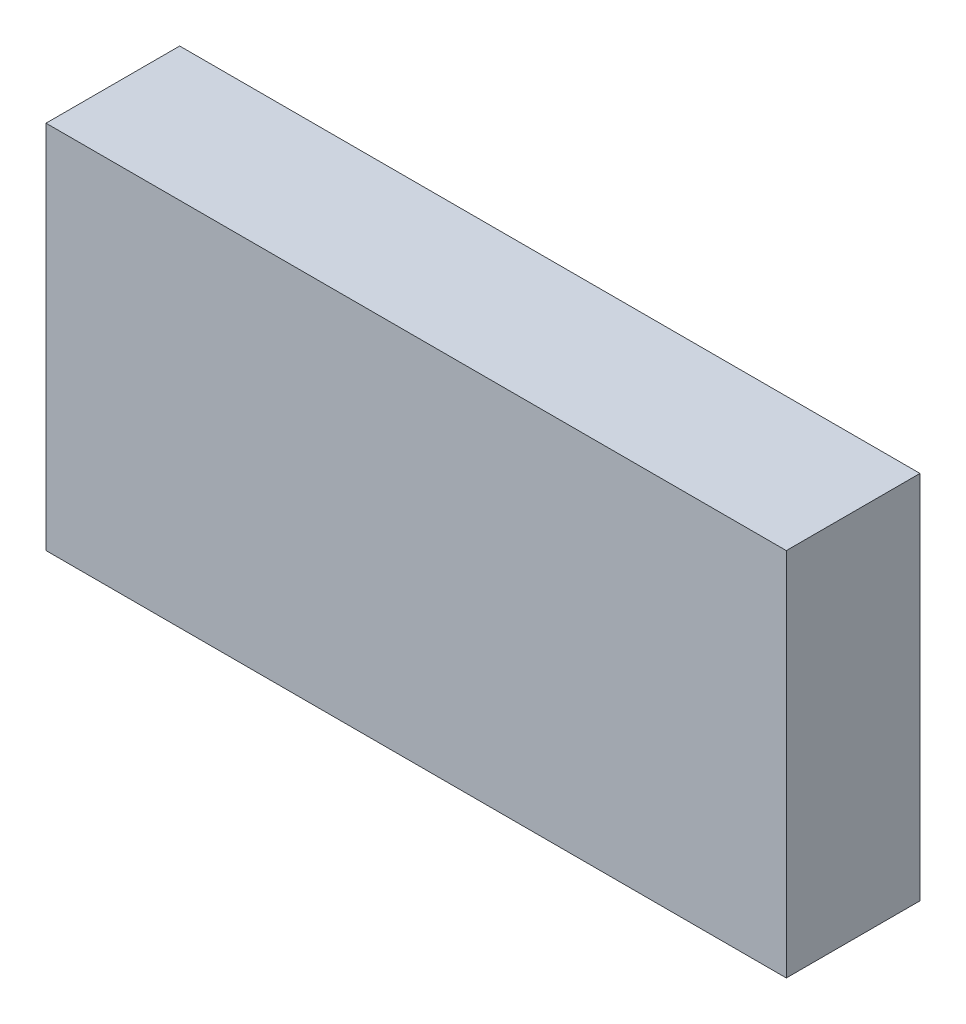
from build123d import *

# Parameters (mm, degrees)
CROQUIS1_W              = 72
CROQUIS1_H              = 36
SALIENTE_EXTRUIR1_DEPTH = 13


with BuildPart() as part:
    # Croquis1 → Saliente-Extruir1 (new body)
    with BuildSketch(Plane.XY):
        Rectangle(CROQUIS1_W, CROQUIS1_H)
    extrude(amount=SALIENTE_EXTRUIR1_DEPTH)


solid = part.part
